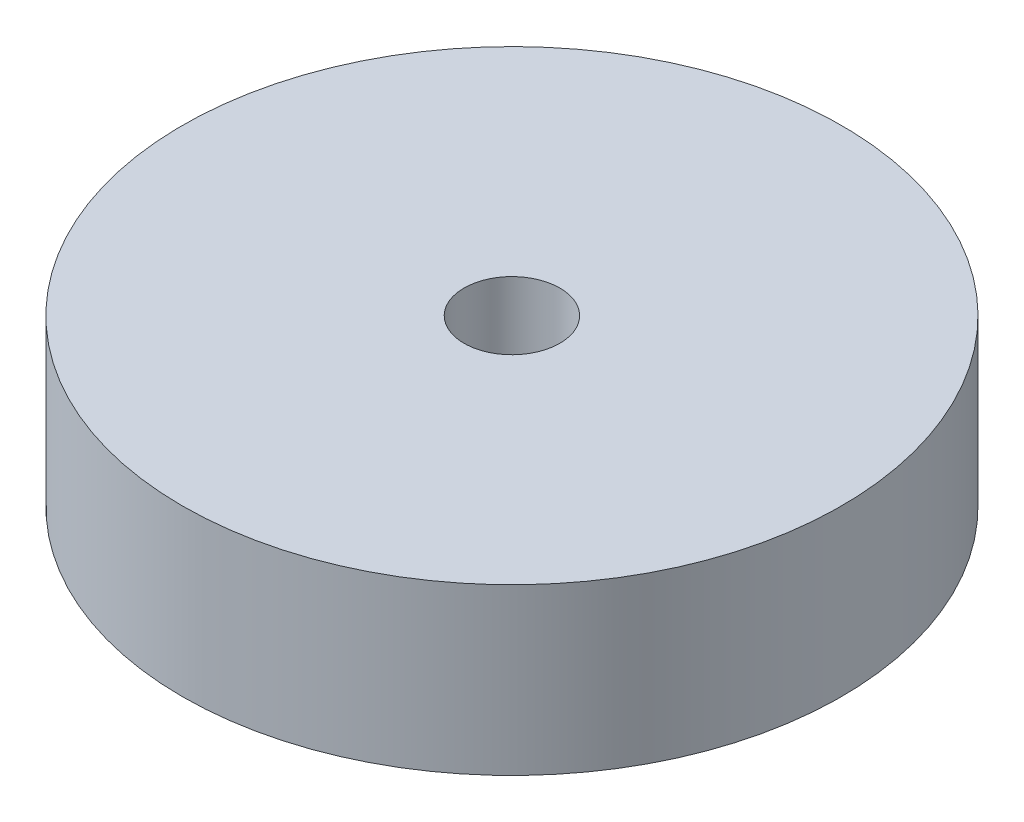
from build123d import *

# Parameters (mm, degrees)
SKETCH1_R           = 19.95
BOSS_EXTRUDE1_DEPTH = 10
SKETCH2_R           = 5.25
CUT_EXTRUDE1_DEPTH  = 5
SKETCH3_R           = 2.9
CUT_EXTRUDE2_DEPTH  = 5


with BuildPart() as part:
    # Sketch1 → Boss-Extrude1 (new body)
    with BuildSketch(Plane(origin=(0, 0, 0), x_dir=(1, 0, 0), z_dir=(0, 1, 0))):
        Circle(SKETCH1_R)
    extrude(amount=BOSS_EXTRUDE1_DEPTH)

    # Sketch2 → Cut-Extrude1 (cut)
    with BuildSketch(Plane(origin=(0, 0, 0), x_dir=(-1, 0, 0), z_dir=(0, -1, 0))):
        Circle(SKETCH2_R)
    extrude(amount=-CUT_EXTRUDE1_DEPTH, mode=Mode.SUBTRACT)

    # Sketch3 → Cut-Extrude2 (cut)
    with BuildSketch(Plane(origin=(0, 5, 0), x_dir=(-1, 0, 0), z_dir=(0, -1, 0))):
        Circle(SKETCH3_R)
    extrude(amount=-CUT_EXTRUDE2_DEPTH, mode=Mode.SUBTRACT)


solid = part.part
